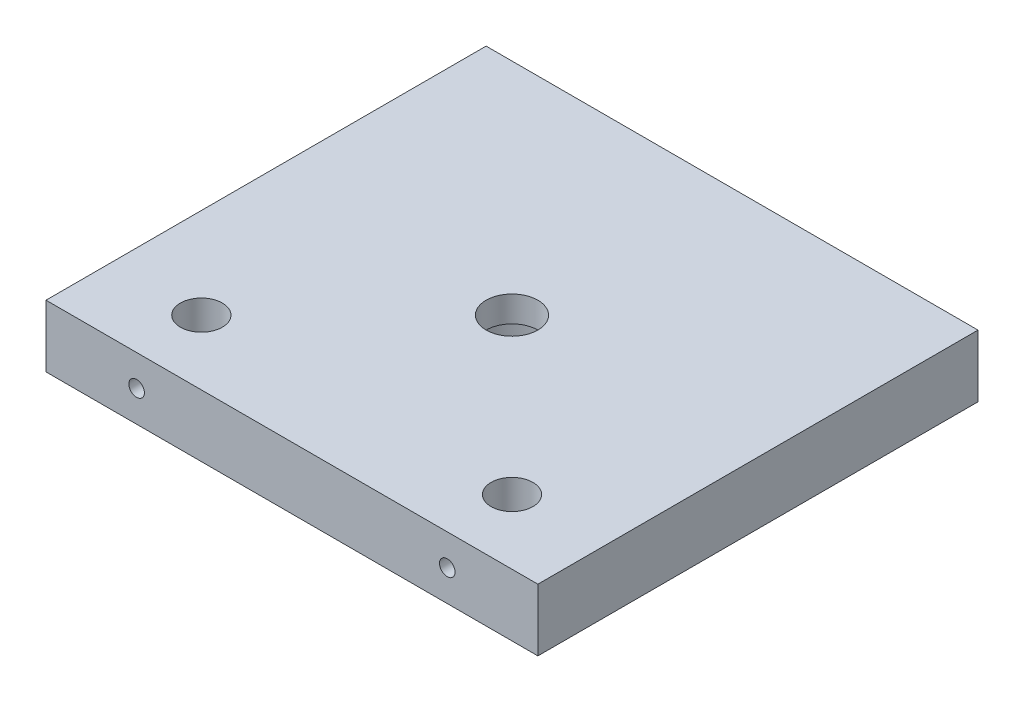
from build123d import *

# Parameters (mm, degrees)
SKETCH1_W           = 95
SKETCH1_H           = 12
BOSS_EXTRUDE1_DEPTH = 85
SKETCH2_R           = 4.05
SKETCH2_R_2         = 5
CUT_EXTRUDE1_DEPTH  = 13
SKETCH3_R           = 11.05
CUT_EXTRUDE2_DEPTH  = 7
CUT_EXTRUDE3_REACH  = 87
SKETCH4_R           = 1.5


with BuildPart() as part:
    # Sketch1 → Boss-Extrude1 (new body)
    with BuildSketch(Plane.XY):
        Rectangle(SKETCH1_W, SKETCH1_H)
    extrude(amount=BOSS_EXTRUDE1_DEPTH)

    # Sketch2 → Cut-Extrude1 (cut, through all)
    with BuildSketch(Plane.XZ.offset(6)):
        with Locations(Location((-30, 72.5, 0), (0, 0, 270))):  # turned: the seam where the file's is
            Circle(SKETCH2_R)
        with Locations(Location((30, 72.5, 0), (0, 0, 270))):  # turned: the seam where the file's is
            Circle(SKETCH2_R)
        with Locations(Location((0, 42.5, 0), (0, 0, 270))):  # turned: the seam where the file's is
            Circle(SKETCH2_R_2)
    extrude(amount=-CUT_EXTRUDE1_DEPTH, mode=Mode.SUBTRACT)

    # Sketch3 → Cut-Extrude2 (cut)
    with BuildSketch(Plane.XZ.offset(6)):
        with Locations(Location((0, 42.5, 0), (0, 0, 270))):  # turned: the seam where the file's is
            Circle(SKETCH3_R)
    extrude(amount=-CUT_EXTRUDE2_DEPTH, mode=Mode.SUBTRACT)

    # Sketch4 → Cut-Extrude3 (cut, up to next)
    with BuildSketch(Plane.XY.offset(85), mode=Mode.PRIVATE) as cut_extrude3_sk1:
        with Locations((30, 0)):
            Circle(SKETCH4_R)
    cut_extrude3_tool1 = extrude(cut_extrude3_sk1.sketch, amount=-CUT_EXTRUDE3_REACH, mode=Mode.PRIVATE) & part.part
    add(cut_extrude3_tool1.solids().sort_by_distance((30, 0, 85))[0], mode=Mode.SUBTRACT)
    # Sketch4 → Cut-Extrude3 (cut, up to next)
    with BuildSketch(Plane.XY.offset(85), mode=Mode.PRIVATE) as cut_extrude3_sk2:
        with Locations((-30, 0)):
            Circle(SKETCH4_R)
    cut_extrude3_tool2 = extrude(cut_extrude3_sk2.sketch, amount=-CUT_EXTRUDE3_REACH, mode=Mode.PRIVATE) & part.part
    add(cut_extrude3_tool2.solids().sort_by_distance((-30, 0, 85))[0], mode=Mode.SUBTRACT)


solid = part.part
